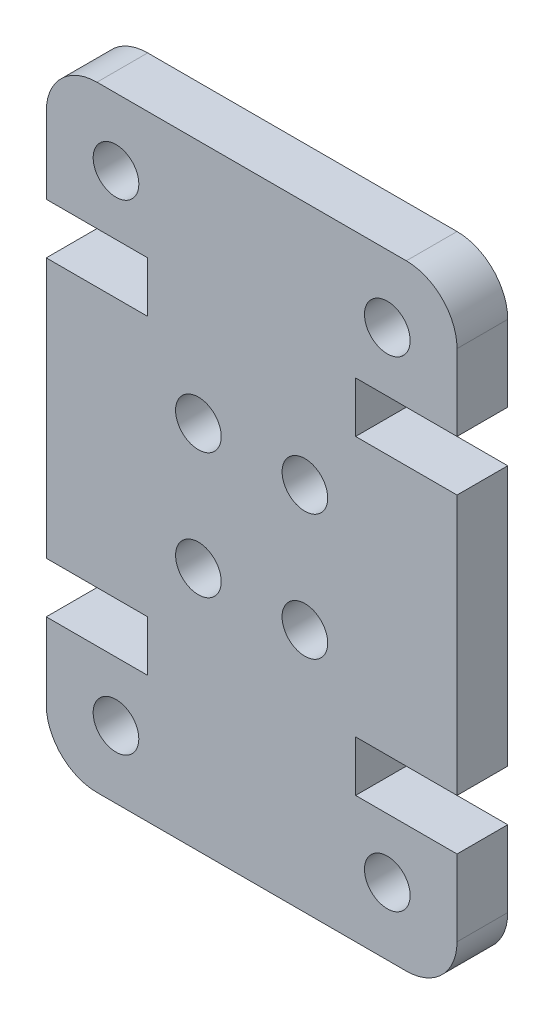
from build123d import *

# Parameters (mm, degrees)
SKETCH1_R           = 0.9
BOSS_EXTRUDE1_DEPTH = 2


with BuildPart() as part:
    # Sketch1 → Boss-Extrude1 (new body)
    with BuildSketch(Plane.XY):
        with BuildLine():
            Line((16.2, 17.26), (16.2, 7))
            Line((16.2, 7), (12.2, 7))
            Line((12.2, 7), (12.2, 5))
            Line((12.2, 5), (16.2, 5))
            Line((16.2, 5), (16.2, 2))
            ThreePointArc((16.2, 2), (15.614213562, 0.585786438), (14.2, 0))
            Line((14.2, 0), (2, 0))
            ThreePointArc((2, 0), (0.585786438, 0.585786438), (0, 2))
            Line((0, 2), (0, 5))
            Line((0, 5), (4, 5))
            Line((4, 5), (4, 7))
            Line((4, 7), (0, 7))
            Line((0, 7), (0, 17.26))
            Line((0, 17.26), (4, 17.26))
            Line((4, 17.26), (4, 19.26))
            Line((4, 19.26), (0, 19.26))
            Line((0, 19.26), (0, 22.26))
            ThreePointArc((0, 22.26), (0.585786438, 23.674213562), (2, 24.26))
            Line((2, 24.26), (14.2, 24.26))
            ThreePointArc((14.2, 24.26), (15.614213562, 23.674213562), (16.2, 22.26))
            Line((16.2, 22.26), (16.2, 19.26))
            Line((16.2, 19.26), (12.2, 19.26))
            Line((12.2, 19.26), (12.2, 17.26))
            Line((12.2, 17.26), (16.2, 17.26))
        make_face()
        with Locations((13.45, 2.653551169)):
            Circle(SKETCH1_R, mode=Mode.SUBTRACT)
        with Locations((10.2, 9.653551169)):
            Circle(SKETCH1_R, mode=Mode.SUBTRACT)
        with Locations((2.75, 21.606448831)):
            Circle(SKETCH1_R, mode=Mode.SUBTRACT)
        with Locations((6, 14.606448831)):
            Circle(SKETCH1_R, mode=Mode.SUBTRACT)
        with Locations((10.2, 14.606448831)):
            Circle(SKETCH1_R, mode=Mode.SUBTRACT)
        with Locations((13.45, 21.606448831)):
            Circle(SKETCH1_R, mode=Mode.SUBTRACT)
        with Locations((6, 9.653551169)):
            Circle(SKETCH1_R, mode=Mode.SUBTRACT)
        with Locations((2.75, 2.653551169)):
            Circle(SKETCH1_R, mode=Mode.SUBTRACT)
    extrude(amount=BOSS_EXTRUDE1_DEPTH)


solid = part.part
